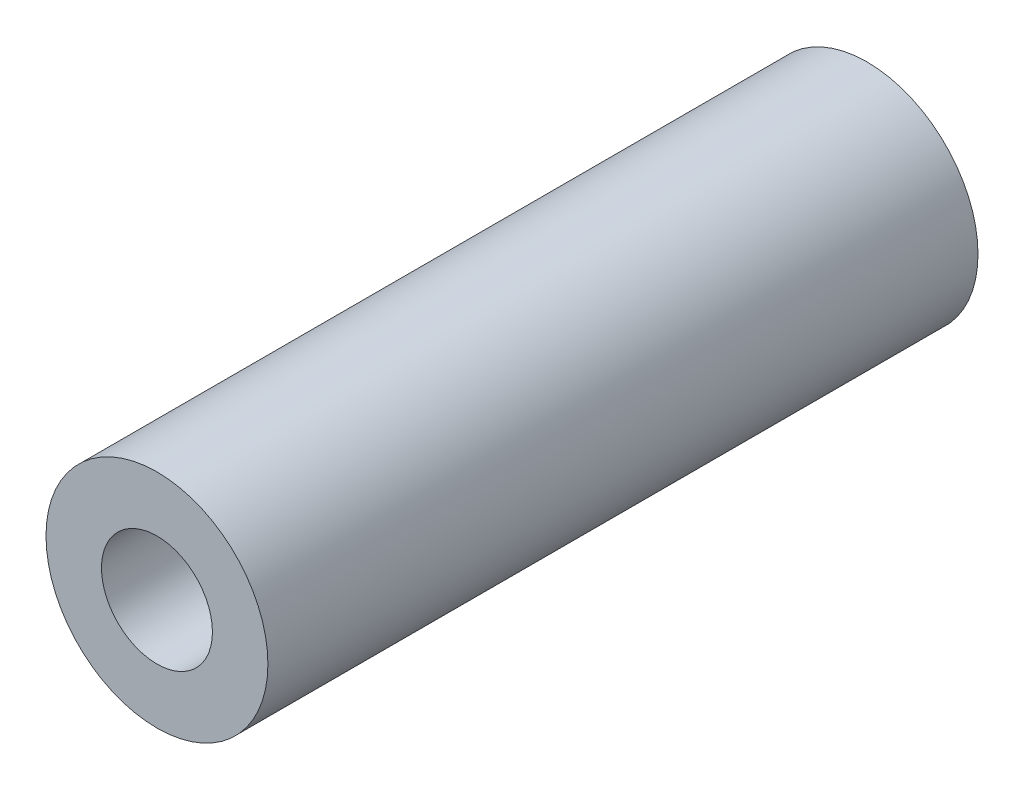
from build123d import *

# Parameters (mm, degrees)
ESQUISSE1_R        = 2.5
ESQUISSE1_R_2      = 1.25
BOSS_EXTRU_1_DEPTH = 16


with BuildPart() as part:
    # Esquisse1 → Boss.-Extru.1 (new body)
    with BuildSketch(Plane.XY):
        Circle(ESQUISSE1_R)
        Circle(ESQUISSE1_R_2, mode=Mode.SUBTRACT)
    extrude(amount=BOSS_EXTRU_1_DEPTH)


solid = part.part
